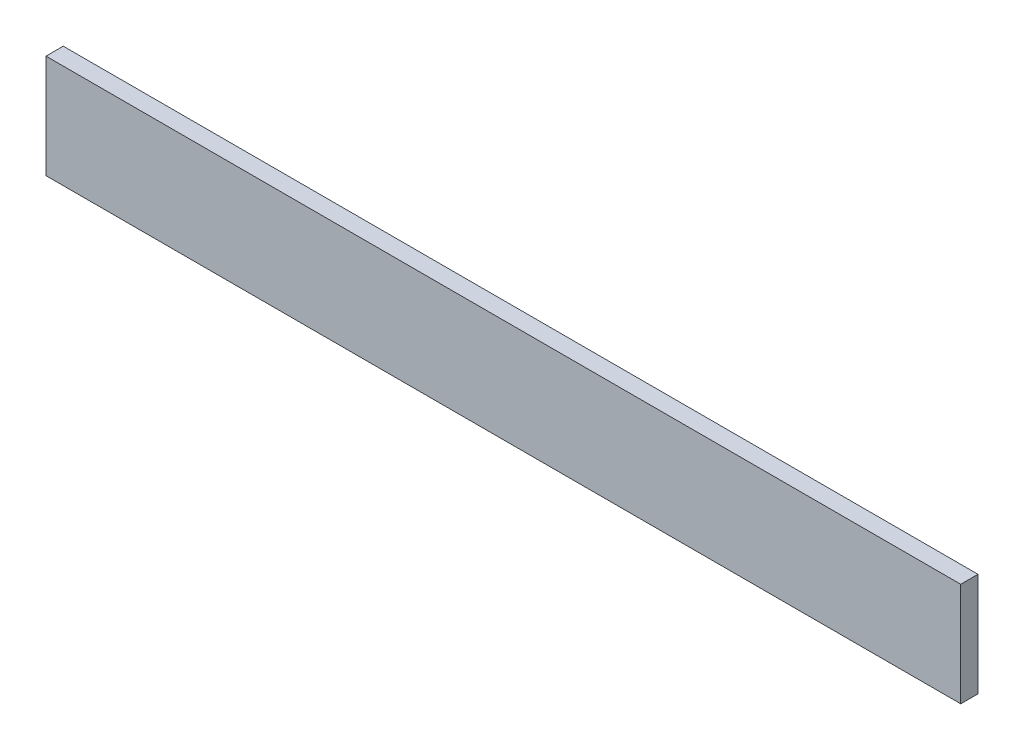
from build123d import *

# Parameters (mm, degrees)
SKETCH1_W           = 265
SKETCH1_H           = 30
BOSS_EXTRUDE1_DEPTH = 5


with BuildPart() as part:
    # Sketch1 → Boss-Extrude1 (new body)
    with BuildSketch(Plane.XY):
        with Locations((132.5, 15)):
            Rectangle(SKETCH1_W, SKETCH1_H)
    extrude(amount=BOSS_EXTRUDE1_DEPTH)


solid = part.part
